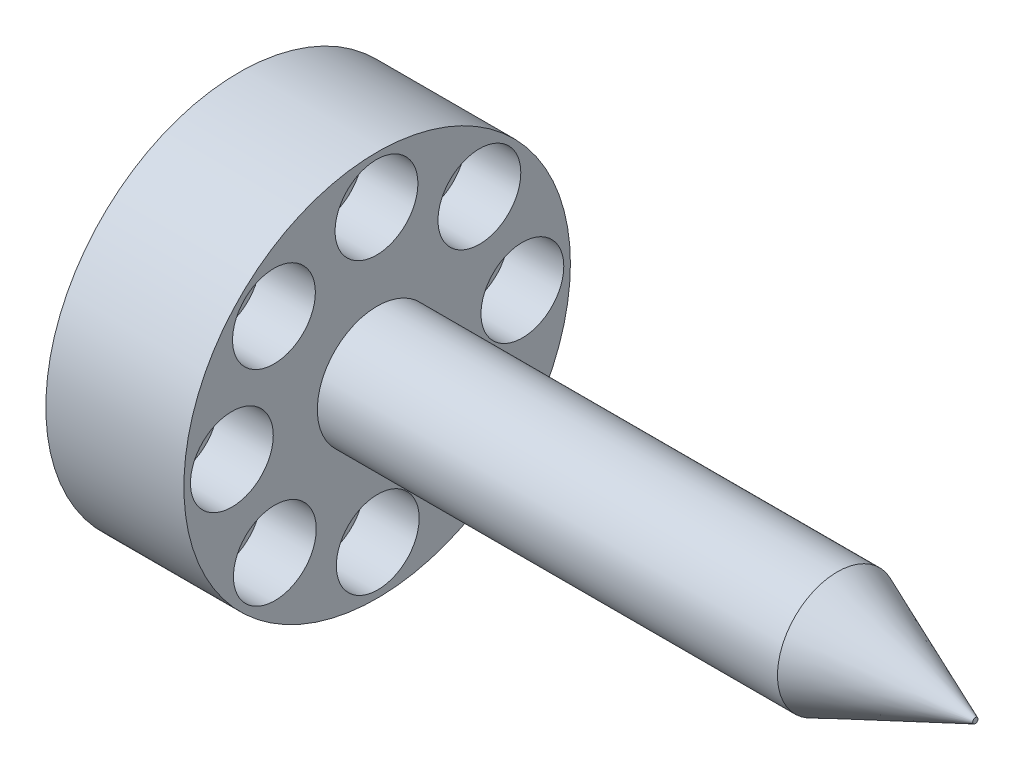
from build123d import *

# Parameters (mm, degrees)
ESBO_O1_R                = 21
RESSALTO_EXTRUS_O1_DEPTH = 15
ESBO_O2_R                = 6.5
RESSALTO_EXTRUS_O2_DEPTH = 65
CHANFRO1_SIZE            = 15
CHANFRO1_SIZE2           = 6.213203436
ESBO_O3_R                = 2.5
CORTE_EXTRUS_O2_DEPTH    = 4000
ESBO_O3_3_R              = 4.5
ESBO_O3_3_R_2            = 2.5
CORTE_EXTRUS_O3_DEPTH    = 6


with BuildPart() as part:
    # Esboço1 → Ressalto-extrusão1 (new body)
    with BuildSketch(Plane(origin=(470, 0, 0), x_dir=(0, 0, -1), z_dir=(1, 0, 0))):
        with Locations((-750, 0)):
            Circle(ESBO_O1_R)
    extrude(amount=RESSALTO_EXTRUS_O1_DEPTH)

    # Esboço2 → Ressalto-extrusão2 (add)
    with BuildSketch(Plane(origin=(485, 0, 0), x_dir=(0, 0, -1), z_dir=(1, 0, 0))):
        with Locations((-750, 0)):
            Circle(ESBO_O2_R)
    extrude(amount=RESSALTO_EXTRUS_O2_DEPTH)

    # Chanfro1
    chanfro1_edges = [part.edges().sort_by_distance(p)[0] for p in [
        (550, 0, 756.5),
    ]]
    chanfro1_side = [part.faces().sort_by_distance(p)[0] for p in [
        (517.5, 0, 756.5),
    ]]
    chamfer(chanfro1_edges, length=CHANFRO1_SIZE, length2=CHANFRO1_SIZE2, reference=chanfro1_side[0])

    # Esboço3 → Corte-extrusão2 (cut)
    with BuildSketch(Plane(origin=(485, 0, 0), x_dir=(0, 0, -1), z_dir=(1, 0, 0))):
        with Locations((-738.884845661, 11.158666767)):
            Circle(ESBO_O3_R)
        with Locations((-734.250030053, 0.030767933)):
            Circle(ESBO_O3_R)
        with Locations((-738.841333233, -11.115154339)):
            Circle(ESBO_O3_R)
        with Locations((-749.969232067, -15.749969947)):
            Circle(ESBO_O3_R)
        with Locations((-761.115154339, -11.158666767)):
            Circle(ESBO_O3_R)
        with Locations((-765.749969947, -0.030767933)):
            Circle(ESBO_O3_R)
        with Locations((-761.158666767, 11.115154339)):
            Circle(ESBO_O3_R)
        with Locations((-750.030767933, 15.749969947)):
            Circle(ESBO_O3_R)
    extrude(amount=-CORTE_EXTRUS_O2_DEPTH, mode=Mode.SUBTRACT)

    # Esboço3<3> → Corte-extrusão3 (cut)
    # profile 1 of 8: a face of its own
    with BuildSketch(Plane(origin=(485, 0, 0), x_dir=(0, 0, -1), z_dir=(1, 0, 0))):
        with Locations((-765.786166925, -0.018086598)):
            Circle(ESBO_O3_3_R)
        with Locations((-765.749969947, -0.030767933)):
            Circle(ESBO_O3_3_R_2, mode=Mode.SUBTRACT)
    # profile 2 of 8: a face of its own
    with BuildSketch(Plane(origin=(485, 0, 0), x_dir=(0, 0, -1), z_dir=(1, 0, 0))):
        with Locations((-761.115154339, -11.158666767)):
            Circle(ESBO_O3_3_R)
        with Locations((-761.115154339, -11.158666767)):
            Circle(ESBO_O3_3_R_2, mode=Mode.SUBTRACT)
    # profile 3 of 8: a face of its own
    with BuildSketch(Plane(origin=(485, 0, 0), x_dir=(0, 0, -1), z_dir=(1, 0, 0))):
        with Locations((-761.211491815, 11.16239786)):
            Circle(ESBO_O3_3_R)
        with Locations((-761.158666767, 11.115154339)):
            Circle(ESBO_O3_3_R_2, mode=Mode.SUBTRACT)
    # profile 4 of 8: a face of its own
    with BuildSketch(Plane(origin=(485, 0, 0), x_dir=(0, 0, -1), z_dir=(1, 0, 0))):
        with Locations((-750.070911646, 15.833410446)):
            Circle(ESBO_O3_3_R)
        with Locations((-750.030767933, 15.749969947)):
            Circle(ESBO_O3_3_R_2, mode=Mode.SUBTRACT)
    # profile 5 of 8: a face of its own
    with BuildSketch(Plane(origin=(485, 0, 0), x_dir=(0, 0, -1), z_dir=(1, 0, 0))):
        with Locations((-738.890427188, 11.258735336)):
            Circle(ESBO_O3_3_R)
        with Locations((-738.884845661, 11.158666767)):
            Circle(ESBO_O3_3_R_2, mode=Mode.SUBTRACT)
    # profile 6 of 8: a face of its own
    with BuildSketch(Plane(origin=(485, 0, 0), x_dir=(0, 0, -1), z_dir=(1, 0, 0))):
        with Locations((-734.219414603, 0.118155167)):
            Circle(ESBO_O3_3_R)
        with Locations((-734.250030053, 0.030767933)):
            Circle(ESBO_O3_3_R_2, mode=Mode.SUBTRACT)
    # profile 7 of 8: a face of its own
    with BuildSketch(Plane(origin=(485, 0, 0), x_dir=(0, 0, -1), z_dir=(1, 0, 0))):
        with Locations((-738.794089712, -11.062329291)):
            Circle(ESBO_O3_3_R)
        with Locations((-738.841333233, -11.115154339)):
            Circle(ESBO_O3_3_R_2, mode=Mode.SUBTRACT)
    # profile 8 of 8: a face of its own
    with BuildSketch(Plane(origin=(485, 0, 0), x_dir=(0, 0, -1), z_dir=(1, 0, 0))):
        with Locations((-749.934669881, -15.733341876)):
            Circle(ESBO_O3_3_R)
        with Locations((-749.969232067, -15.749969947)):
            Circle(ESBO_O3_3_R_2, mode=Mode.SUBTRACT)
    extrude(amount=-CORTE_EXTRUS_O3_DEPTH, mode=Mode.SUBTRACT)


solid = part.part
